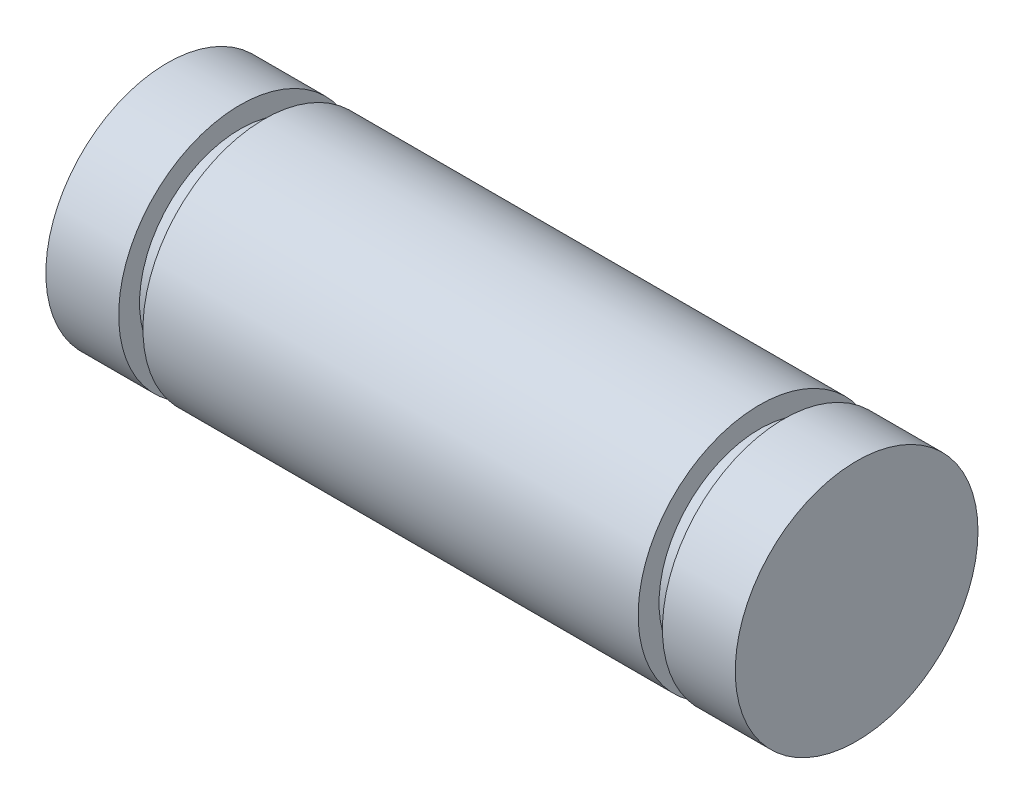
from build123d import *

# Parameters (mm, degrees)
SKETCH1_R      = 3.175
EXTRUDE1_DEPTH = 9.017
SKETCH2_W      = 0.635
SKETCH2_H      = 0.5461


with BuildPart() as part:
    # Sketch1 → Extrude1 (new body, symmetric)
    with BuildSketch(Plane(origin=(0, 0, 0), x_dir=(0, 0, -1), z_dir=(1, 0, 0))):
        Circle(SKETCH1_R)
    extrude(amount=EXTRUDE1_DEPTH, both=True)

    # Sketch2 → Cut-Revolve1 (revolve, cut)
    with BuildSketch(Plane.XY):
        with Locations((-6.7945, 2.90195)):
            Rectangle(SKETCH2_W, SKETCH2_H)
        with Locations((6.7945, 2.90195)):
            Rectangle(SKETCH2_W, SKETCH2_H)
    revolve(axis=Axis((0, 0, 0), (-1, 0, 0)), mode=Mode.SUBTRACT)


solid = part.part
